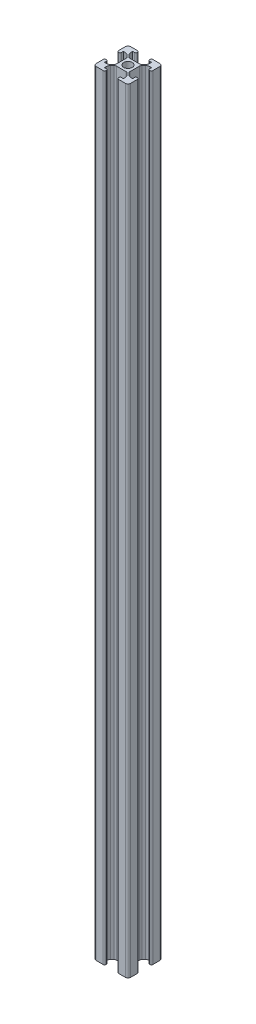
from build123d import *

# Parameters (mm, degrees)
SKETCH2_R           = 2.5
BOSS_EXTRUDE1_DEPTH = 450


with BuildPart() as part:
    # Sketch2 → Boss-Extrude1 (new body)
    with BuildSketch(Plane(origin=(0, 0, 0), x_dir=(1, 0, 0), z_dir=(0, 1, 0))):
        with BuildLine():
            Line((-5.4, 4.869669914), (-4.339339828, 3.809009742))
            ThreePointArc((-4.339339828, 3.809009742), (-4.014180701, 3.322374719), (-3.9, 2.748349571))
            Line((-3.9, 2.748349571), (-3.9, -2.748349571))
            ThreePointArc((-3.9, -2.748349571), (-4.014180701, -3.322374719), (-4.339339828, -3.809009742))
            Line((-4.339339828, -3.809009742), (-5.4, -4.869669914))
            ThreePointArc((-5.4, -4.869669914), (-6.246412561, -5.337861749), (-7.2, -5.5))
            Line((-7.2, -5.5), (-8.2, -5.5))
            Line((-8.2, -5.5), (-8.2, -4.4))
            ThreePointArc((-8.2, -4.4), (-8.434314575, -3.834314575), (-9, -3.6))
            Line((-9, -3.6), (-9.2, -3.6))
            ThreePointArc((-9.2, -3.6), (-9.765685425, -3.834314575), (-10, -4.4))
            Line((-10, -4.4), (-10, -8.5))
            ThreePointArc((-10, -8.5), (-9.560660172, -9.560660172), (-8.5, -10))
            Line((-8.5, -10), (-4.4, -10))
            ThreePointArc((-4.4, -10), (-3.834314575, -9.765685425), (-3.6, -9.2))
            Line((-3.6, -9.2), (-3.6, -9))
            ThreePointArc((-3.6, -9), (-3.834314575, -8.434314575), (-4.4, -8.2))
            Line((-4.4, -8.2), (-5.5, -8.2))
            Line((-5.5, -8.2), (-5.5, -7.2))
            ThreePointArc((-5.5, -7.2), (-5.337861749, -6.246412561), (-4.869669914, -5.4))
            Line((-4.869669914, -5.4), (-3.809009742, -4.339339828))
            ThreePointArc((-3.809009742, -4.339339828), (-3.322374719, -4.014180701), (-2.748349571, -3.9))
            Line((-2.748349571, -3.9), (2.748349571, -3.9))
            ThreePointArc((2.748349571, -3.9), (3.322374719, -4.014180701), (3.809009742, -4.339339828))
            Line((3.809009742, -4.339339828), (4.869669914, -5.4))
            ThreePointArc((4.869669914, -5.4), (5.337861749, -6.246412561), (5.5, -7.2))
            Line((5.5, -7.2), (5.5, -8.2))
            Line((5.5, -8.2), (4.4, -8.2))
            ThreePointArc((4.4, -8.2), (3.834314575, -8.434314575), (3.6, -9))
            Line((3.6, -9), (3.6, -9.2))
            ThreePointArc((3.6, -9.2), (3.834314575, -9.765685425), (4.4, -10))
            Line((4.4, -10), (8.5, -10))
            ThreePointArc((8.5, -10), (9.560660172, -9.560660172), (10, -8.5))
            Line((10, -8.5), (10, -4.4))
            ThreePointArc((10, -4.4), (9.765685425, -3.834314575), (9.2, -3.6))
            Line((9.2, -3.6), (9, -3.6))
            ThreePointArc((9, -3.6), (8.434314575, -3.834314575), (8.2, -4.4))
            Line((8.2, -4.4), (8.2, -5.5))
            Line((8.2, -5.5), (7.2, -5.5))
            ThreePointArc((7.2, -5.5), (6.246412561, -5.337861749), (5.4, -4.869669914))
            Line((5.4, -4.869669914), (4.339339828, -3.809009742))
            ThreePointArc((4.339339828, -3.809009742), (4.014180701, -3.322374719), (3.9, -2.748349571))
            Line((3.9, -2.748349571), (3.9, 2.748349571))
            ThreePointArc((3.9, 2.748349571), (4.014180701, 3.322374719), (4.339339828, 3.809009742))
            Line((4.339339828, 3.809009742), (5.4, 4.869669914))
            ThreePointArc((5.4, 4.869669914), (6.246412561, 5.337861749), (7.2, 5.5))
            Line((7.2, 5.5), (8.2, 5.5))
            Line((8.2, 5.5), (8.2, 4.4))
            ThreePointArc((8.2, 4.4), (8.434314575, 3.834314575), (9, 3.6))
            Line((9, 3.6), (9.2, 3.6))
            ThreePointArc((9.2, 3.6), (9.765685425, 3.834314575), (10, 4.4))
            Line((10, 4.4), (10, 8.5))
            ThreePointArc((10, 8.5), (9.560660172, 9.560660172), (8.5, 10))
            Line((8.5, 10), (4.4, 10))
            ThreePointArc((4.4, 10), (3.834314575, 9.765685425), (3.6, 9.2))
            Line((3.6, 9.2), (3.6, 9))
            ThreePointArc((3.6, 9), (3.834314575, 8.434314575), (4.4, 8.2))
            Line((4.4, 8.2), (5.5, 8.2))
            Line((5.5, 8.2), (5.5, 7.2))
            ThreePointArc((5.5, 7.2), (5.337861749, 6.246412561), (4.869669914, 5.4))
            Line((4.869669914, 5.4), (3.809009742, 4.339339828))
            ThreePointArc((3.809009742, 4.339339828), (3.322374719, 4.014180701), (2.748349571, 3.9))
            Line((2.748349571, 3.9), (-2.748349571, 3.9))
            ThreePointArc((-2.748349571, 3.9), (-3.322374719, 4.014180701), (-3.809009742, 4.339339828))
            Line((-3.809009742, 4.339339828), (-4.869669914, 5.4))
            ThreePointArc((-4.869669914, 5.4), (-5.337861749, 6.246412561), (-5.5, 7.2))
            Line((-5.5, 7.2), (-5.5, 8.2))
            Line((-5.5, 8.2), (-4.4, 8.2))
            ThreePointArc((-4.4, 8.2), (-3.834314575, 8.434314575), (-3.6, 9))
            Line((-3.6, 9), (-3.6, 9.2))
            ThreePointArc((-3.6, 9.2), (-3.834314575, 9.765685425), (-4.4, 10))
            Line((-4.4, 10), (-8.5, 10))
            ThreePointArc((-8.5, 10), (-9.560660172, 9.560660172), (-10, 8.5))
            Line((-10, 8.5), (-10, 4.4))
            ThreePointArc((-10, 4.4), (-9.765685425, 3.834314575), (-9.2, 3.6))
            Line((-9.2, 3.6), (-9, 3.6))
            ThreePointArc((-9, 3.6), (-8.434314575, 3.834314575), (-8.2, 4.4))
            Line((-8.2, 4.4), (-8.2, 5.5))
            Line((-8.2, 5.5), (-7.2, 5.5))
            ThreePointArc((-7.2, 5.5), (-6.246412561, 5.337861749), (-5.4, 4.869669914))
        make_face()
        Circle(SKETCH2_R, mode=Mode.SUBTRACT)
    extrude(amount=BOSS_EXTRUDE1_DEPTH)


solid = part.part
